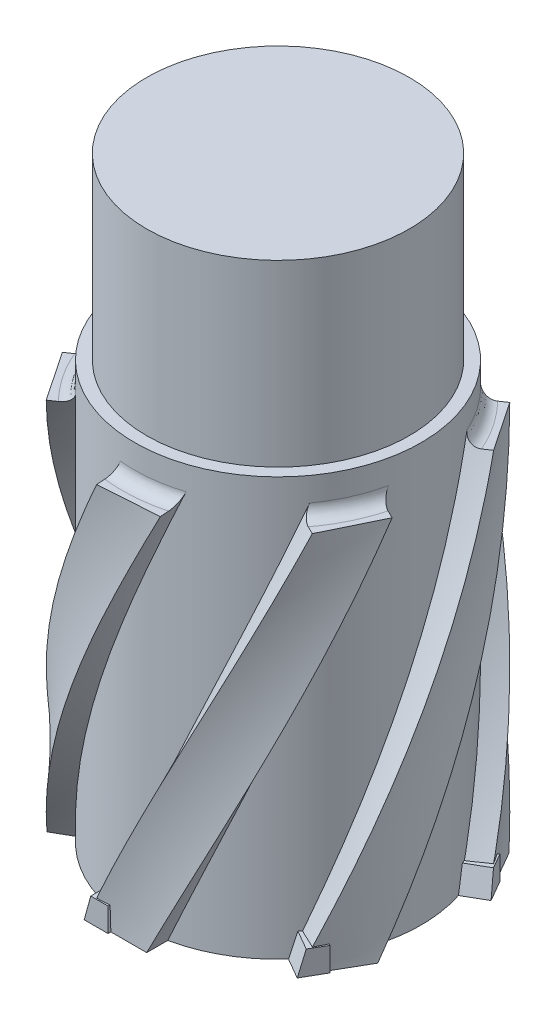
from build123d import *

# Parameters (mm, degrees)
SKETCH_1_R                       = 11
EXTRUDE_1_DEPTH                  = 50
SKETCH_2_R                       = 12
EXTRUDE_2_DEPTH                  = 35
SWEEP_1_PITCH                    = 180
SWEEP_1_HEIGHT                   = 32
SWEEP_1_RADIUS                   = 12
SWEEP_1_START_ANGLE              = -180
SKETCH_4_W                       = 5
SKETCH_4_H                       = 3
FILLET_1_R                       = 1
PATTERN_CIRCULAR_8_COUNT         = 6
FILLET_1_OF_PATTERN_CIRCULAR_8_R = 1
SKETCH_6_W                       = 2
SKETCH_6_H                       = 2
EXTRUDE_3_DEPTH                  = 2
CUT_EXTRUDE_2_DEPTH              = 2
SKETCH_5_R                       = 10
CUT_EXTRUDE_1_DEPTH              = 48
PATTERN_CIRCULAR_4_COUNT         = 6


with BuildPart() as part:
    # 草图1 → 凸台-拉伸1 (new body)
    with BuildSketch(Plane(origin=(0, 0, 0), x_dir=(1, 0, 0), z_dir=(0, 1, 0))):
        with Locations(Location((0, 0, 0), (0, 0, 270))):
            Circle(SKETCH_1_R)
    extrude(amount=EXTRUDE_1_DEPTH)

    # 草图2 → 凸台-拉伸2 (add)
    with BuildSketch(Plane.XZ):
        with Locations(Location((0, 0, 0), (0, 0, 270))):
            Circle(SKETCH_2_R)
    extrude(amount=-EXTRUDE_2_DEPTH)

    # 扫描1: sweep along a helix
    with BuildLine() as sweep_1_path:
        add(Helix(SWEEP_1_PITCH, SWEEP_1_HEIGHT, SWEEP_1_RADIUS, center=(0, 0, 0), direction=(0, 1, 0), mode=Mode.PRIVATE).rotate(Axis((0, 0, 0), (0, 1, 0)), SWEEP_1_START_ANGLE))
    # 草图4 → 扫描1 (sweep)
    with BuildSketch(Plane.XZ):
        with Locations((0, -12)):
            Rectangle(SKETCH_4_W, SKETCH_4_H)
    sweep_1 = sweep(path=sweep_1_path.line, is_frenet=True)

    # 圆角1
    fillet_1_edges = [part.edges().sort_by_distance(p)[0] for p in [
        (-10.785528555, 32.000000031, -5.260453763),
    ]]
    fillet(fillet_1_edges, radius=FILLET_1_R)

    # 阵列(圆周)8: 扫描1 ×6 about axis
    pattern_circular_8_axis = Axis((0, 35, 0), (0, -1, 0))
    for i in range(1, PATTERN_CIRCULAR_8_COUNT):
        add(sweep_1.rotate(pattern_circular_8_axis, i * 360 / PATTERN_CIRCULAR_8_COUNT))

    # 圆角1 of 阵列(圆周)8
    fillet_1_of_pattern_circular_8_edges = [part.edges().sort_by_distance(p)[0] for p in [
        (-0.837077683, 32.000000031, -11.970768603),
        (9.948450872, 32.000000031, -6.71031484),
        (10.785528555, 32.000000031, 5.260453763),
        (0.837077683, 32.000000031, 11.970768603),
        (-9.948450872, 32.000000031, 6.71031484),
    ]]
    fillet(fillet_1_of_pattern_circular_8_edges, radius=FILLET_1_OF_PATTERN_CIRCULAR_8_R)


with BuildPart() as body_2:
    # 草图6 → 凸台-拉伸3 (new body)
    with BuildSketch(Plane(origin=(2.5, 0, 0), x_dir=(0, 0, -1), z_dir=(1, 0, 0))):
        with Locations((12.736694594, 1)):
            Rectangle(SKETCH_6_W, SKETCH_6_H)
    extrude(amount=-EXTRUDE_3_DEPTH)


with BuildPart() as cut_extrude_2_tool:
    # 草图7 → 切除-拉伸2 (new body)
    with BuildSketch(Plane(origin=(0, 0, -13.736694594), x_dir=(-1, 0, 0), z_dir=(0, 0, -1))):
        Polygon((-2.5, 0), (-1.948577361, 2), (-2.5, 2), align=None)
    extrude(amount=-CUT_EXTRUDE_2_DEPTH)


with BuildPart() as part_1:
    add(part.part)

    # 切除-拉伸2: cut by cut_extrude_2_tool
    add(cut_extrude_2_tool.part, mode=Mode.SUBTRACT)

    # 草图5 → 切除-拉伸1 (cut)
    with BuildSketch(Plane.XZ):
        with Locations(Location((0, 0, 0), (0, 0, 270))):
            Circle(SKETCH_5_R)
    extrude(amount=-CUT_EXTRUDE_1_DEPTH, mode=Mode.SUBTRACT)


with BuildPart() as body_2_1:
    add(body_2.part)

    # 切除-拉伸2: cut by cut_extrude_2_tool
    add(cut_extrude_2_tool.part, mode=Mode.SUBTRACT)


with BuildPart() as pattern_circular_4_1:
    # 阵列(圆周)4: pattern copy
    add(body_2_1.part.rotate(Axis((0, 0, 0), (0, 1, 0)), 1 * 360 / PATTERN_CIRCULAR_4_COUNT))


with BuildPart() as pattern_circular_4_2:
    # 阵列(圆周)4: pattern copy
    add(body_2_1.part.rotate(Axis((0, 0, 0), (0, 1, 0)), 2 * 360 / PATTERN_CIRCULAR_4_COUNT))


with BuildPart() as pattern_circular_4_3:
    # 阵列(圆周)4: pattern copy
    add(body_2_1.part.rotate(Axis((0, 0, 0), (0, 1, 0)), 3 * 360 / PATTERN_CIRCULAR_4_COUNT))


with BuildPart() as pattern_circular_4_4:
    # 阵列(圆周)4: pattern copy
    add(body_2_1.part.rotate(Axis((0, 0, 0), (0, 1, 0)), 4 * 360 / PATTERN_CIRCULAR_4_COUNT))


with BuildPart() as pattern_circular_4_5:
    # 阵列(圆周)4: pattern copy
    add(body_2_1.part.rotate(Axis((0, 0, 0), (0, 1, 0)), 5 * 360 / PATTERN_CIRCULAR_4_COUNT))


solid = Compound([part_1.part, body_2_1.part, pattern_circular_4_1.part, pattern_circular_4_2.part, pattern_circular_4_3.part, pattern_circular_4_4.part, pattern_circular_4_5.part])
